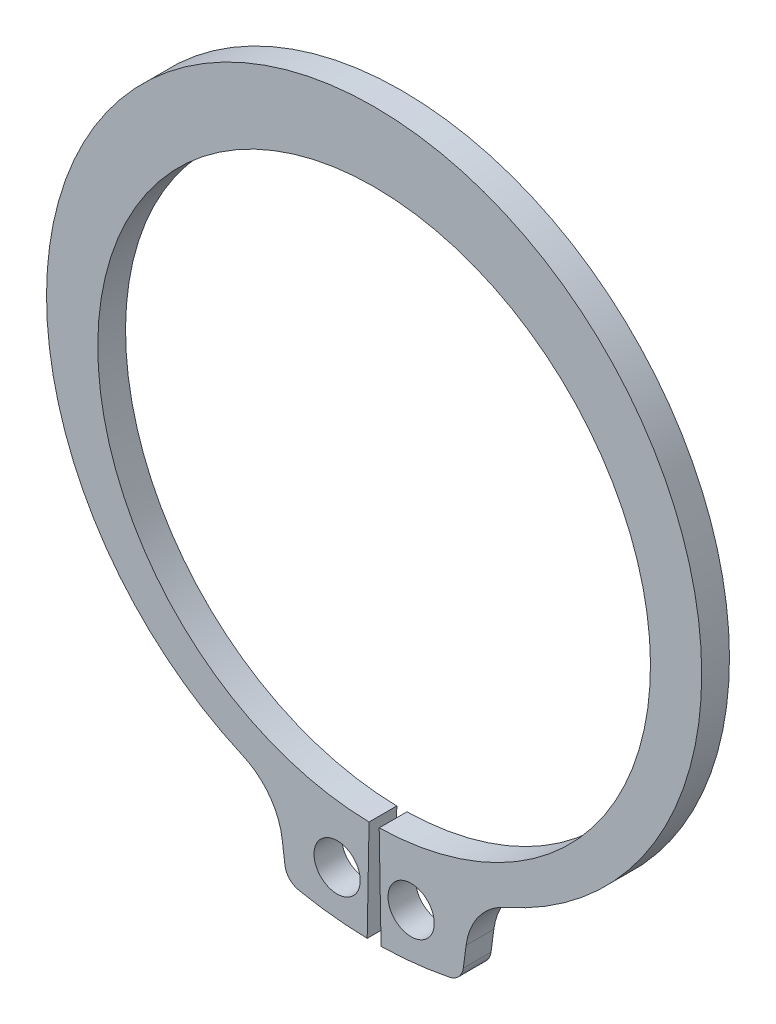
from build123d import *

# Parameters (mm, degrees)
BODYSKE_R  = 1
BODY_DEPTH = 1.2


with BuildPart() as part:
    # BodySke → Body (new body)
    with BuildSketch(Plane.XY):
        with BuildLine():
            Line((0.219266055, -11.947988215), (0.3, -16.347247475))
            ThreePointArc((0.3, -16.347247475), (1.788546664, -16.251879917), (3.262207648, -16.021251551))
            ThreePointArc((3.262207648, -16.021251551), (3.661120947, -15.797787011), (3.856148742, -15.384226399))
            Line((3.856148742, -15.384226399), (3.976937036, -14.466748214))
            ThreePointArc((3.976937036, -14.466748214), (4.533353182, -13.10377966), (5.68742579, -12.189778225))
            ThreePointArc((5.68742579, -12.189778225), (0, 14.95), (-5.68742579, -12.189778225))
            ThreePointArc((-5.68742579, -12.189778225), (-4.533353182, -13.10377966), (-3.976937036, -14.466748214))
            Line((-3.976937036, -14.466748214), (-3.856148742, -15.384226399))
            ThreePointArc((-3.856148742, -15.384226399), (-3.661120947, -15.797787011), (-3.262207648, -16.021251551))
            ThreePointArc((-3.262207648, -16.021251551), (-1.788546664, -16.251879917), (-0.3, -16.347247475))
            Line((-0.3, -16.347247475), (-0.219266055, -11.947988215))
            ThreePointArc((-0.219266055, -11.947988215), (0, 11.95), (0.219266055, -11.947988215))
        make_face()
        with Locations((1.6, -14.335990548)):
            Circle(BODYSKE_R, mode=Mode.SUBTRACT)
        with Locations((-1.6, -14.335990548)):
            Circle(BODYSKE_R, mode=Mode.SUBTRACT)
    extrude(amount=-BODY_DEPTH)


solid = part.part
